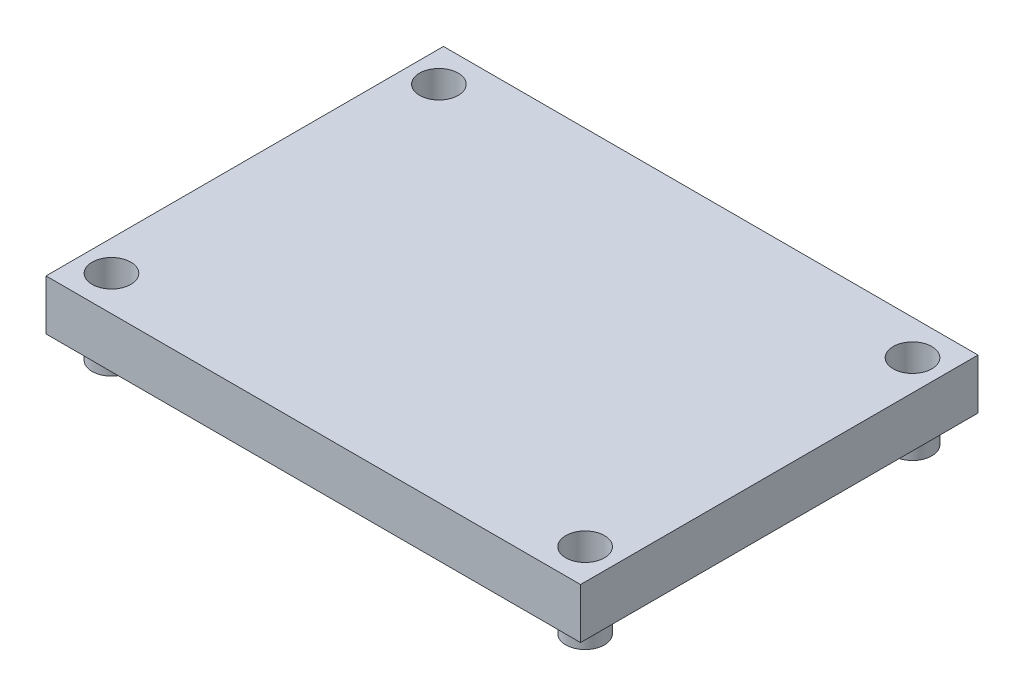
from build123d import *

# Parameters (mm, degrees)
SKETCH1_W             = 70.2
SKETCH1_H             = 52.2
SKETCH1_R             = 2.54
BOSS_EXTRUDE1_DEPTH   = 6.604
SKETCH1_2_R           = 2.54
BOSS_EXTRUDE2_DEPTH   = 3.302
BOSS_EXTRUDE2_2_DEPTH = 3.302
BOSS_EXTRUDE2_3_DEPTH = 3.302
BOSS_EXTRUDE2_4_DEPTH = 3.302


with BuildPart() as part:
    # Sketch1 → Boss-Extrude1 (new body)
    with BuildSketch(Plane(origin=(0, 0, 0), x_dir=(1, 0, 0), z_dir=(0, 1, 0))):
        with Locations((35.1, -26.1)):
            Rectangle(SKETCH1_W, SKETCH1_H)
        with Locations((4, -4.6)):
            Circle(SKETCH1_R, mode=Mode.SUBTRACT)
        with Locations((66.2, -4.6)):
            Circle(SKETCH1_R, mode=Mode.SUBTRACT)
        with Locations((66.2, -47.6)):
            Circle(SKETCH1_R, mode=Mode.SUBTRACT)
        with Locations((4, -47.6)):
            Circle(SKETCH1_R, mode=Mode.SUBTRACT)
    extrude(amount=BOSS_EXTRUDE1_DEPTH)


with BuildPart() as body_2:
    # Sketch1_2 → Boss-Extrude2 (new body)
    with BuildSketch(Plane(origin=(0, 0, 0), x_dir=(1, 0, 0), z_dir=(0, 1, 0))):
        with Locations((4, -4.6)):
            Circle(SKETCH1_2_R)
    extrude(amount=-BOSS_EXTRUDE2_DEPTH)


with BuildPart() as body_3:
    # Sketch1_2 → Boss-Extrude2 2 (new body)
    with BuildSketch(Plane(origin=(0, 0, 0), x_dir=(1, 0, 0), z_dir=(0, 1, 0))):
        with Locations((66.2, -4.6)):
            Circle(SKETCH1_2_R)
    extrude(amount=-BOSS_EXTRUDE2_2_DEPTH)


with BuildPart() as body_4:
    # Sketch1_2 → Boss-Extrude2 3 (new body)
    with BuildSketch(Plane(origin=(0, 0, 0), x_dir=(1, 0, 0), z_dir=(0, 1, 0))):
        with Locations((66.2, -47.6)):
            Circle(SKETCH1_2_R)
    extrude(amount=-BOSS_EXTRUDE2_3_DEPTH)


with BuildPart() as body_5:
    # Sketch1_2 → Boss-Extrude2 4 (new body)
    with BuildSketch(Plane(origin=(0, 0, 0), x_dir=(1, 0, 0), z_dir=(0, 1, 0))):
        with Locations((4, -47.6)):
            Circle(SKETCH1_2_R)
    extrude(amount=-BOSS_EXTRUDE2_4_DEPTH)


solid = Compound([part.part, body_2.part, body_3.part, body_4.part, body_5.part])
